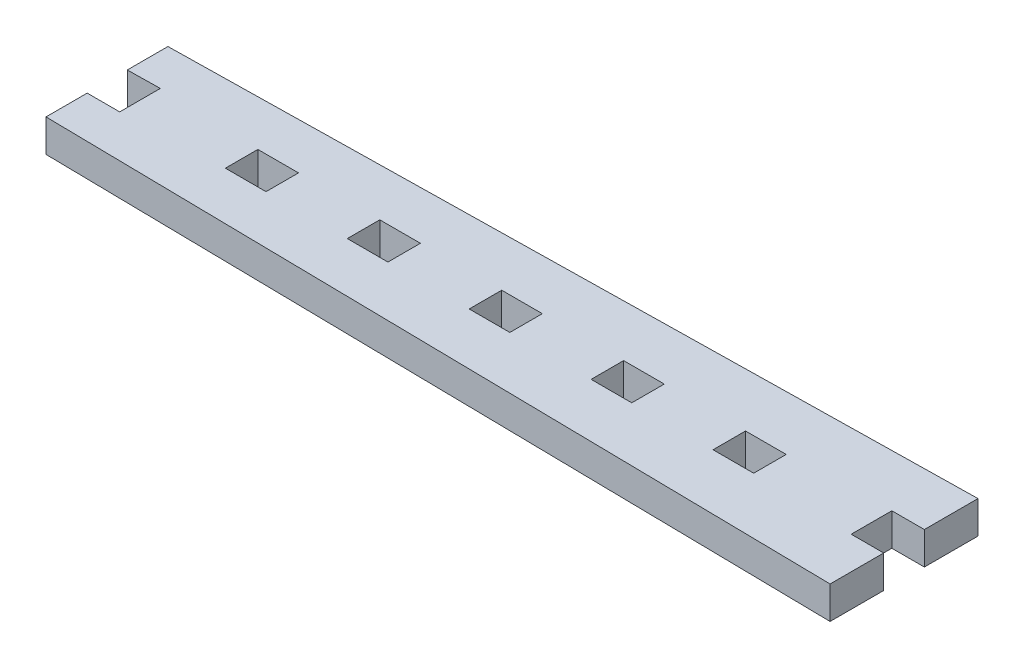
from build123d import *

# Parameters (mm, degrees)
BOSS_EXTRUDE1_DEPTH = 5.08
SKETCH2_W           = 6.35
SKETCH2_H           = 5.08
CUT_EXTRUDE1_DEPTH  = 6.08
LPATTERN1_COUNT     = 5
LPATTERN1_PITCH     = 19.05


with BuildPart() as part:
    # Sketch1 → Boss-Extrude1 (new body)
    with BuildSketch(Plane(origin=(0, 0, 0), x_dir=(1, 0, 0), z_dir=(0, 1, 0))):
        Polygon((-0.444494962, 12.618026496), (-0.444494962, 18.96894547), (124.014769965, 21.086442969), (124.014769965, 12.704442969), (118.934769965, 12.704442969), (118.934769965, 6.354442969), (124.014769965, 6.354442969), (124.014769965, -2.027557031), (-0.445230035, -0.081054515), (-0.445230035, 6.354442969), (4.634769965, 6.354442969), (4.634769965, 12.704442969), align=None)
    extrude(amount=BOSS_EXTRUDE1_DEPTH)

    # Sketch2 → Cut-Extrude1 (cut, through all)
    with BuildSketch(Plane(origin=(0, 5.08, 0), x_dir=(1, 0, 0), z_dir=(0, 1, 0))):
        with Locations((23.684769965, 9.529442969)):
            Rectangle(SKETCH2_W, SKETCH2_H)
    cut_extrude1 = extrude(amount=-CUT_EXTRUDE1_DEPTH, mode=Mode.SUBTRACT)

    # LPattern1: Cut-Extrude1 ×5
    with Locations(*[(i * LPATTERN1_PITCH, 0, 0) for i in range(1, LPATTERN1_COUNT)]):
        add(cut_extrude1, mode=Mode.SUBTRACT)


solid = part.part
